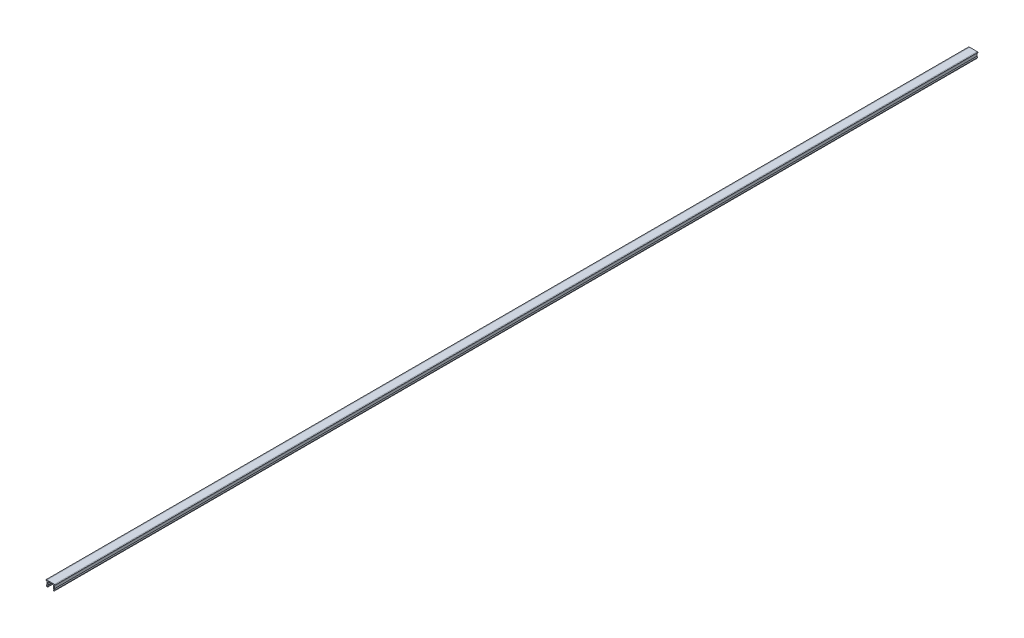
from build123d import *

# Parameters (mm, degrees)
EXTRUDE_1_DEPTH = 1000


with BuildPart() as part:
    # Эскиз1 → Бобышка-Вытянуть1 (new body)
    with BuildSketch(Plane.XY):
        with BuildLine():
            Line((-4.1, 0), (-5, -0.158694283))
            Line((-5, -0.158694283), (-5, -0.8))
            Line((-5, -0.8), (-4.1, -0.8))
            Line((-4.1, -0.8), (-4.1, -4.196152423))
            Line((-4.1, -4.196152423), (-4.68771324, -5.214101615))
            Line((-4.68771324, -5.214101615), (-4.1, -6.232050808))
            ThreePointArc((-4.1, -6.232050808), (-3.497197677, -6.481739705), (-3.1, -5.964101615))
            Line((-3.1, -5.964101615), (-3.533012702, -5.214101615))
            Line((-3.533012702, -5.214101615), (-3.1, -4.464101615))
            Line((-3.1, -4.464101615), (-3.1, -1))
            Line((-3.1, -1), (3.1, -1))
            Line((3.1, -1), (3.1, -4.464101615))
            Line((3.1, -4.464101615), (3.533012702, -5.214101615))
            Line((3.533012702, -5.214101615), (3.1, -5.964101615))
            ThreePointArc((3.1, -5.964101615), (3.497197677, -6.481739705), (4.1, -6.232050808))
            Line((4.1, -6.232050808), (4.68771324, -5.214101615))
            Line((4.68771324, -5.214101615), (4.1, -4.196152423))
            Line((4.1, -4.196152423), (4.1, -0.8))
            Line((4.1, -0.8), (5, -0.8))
            Line((5, -0.8), (5, -0.158694283))
            Line((5, -0.158694283), (4.1, 0))
            Line((4.1, 0), (-4.1, 0))
        make_face()
    extrude(amount=EXTRUDE_1_DEPTH)


solid = part.part
